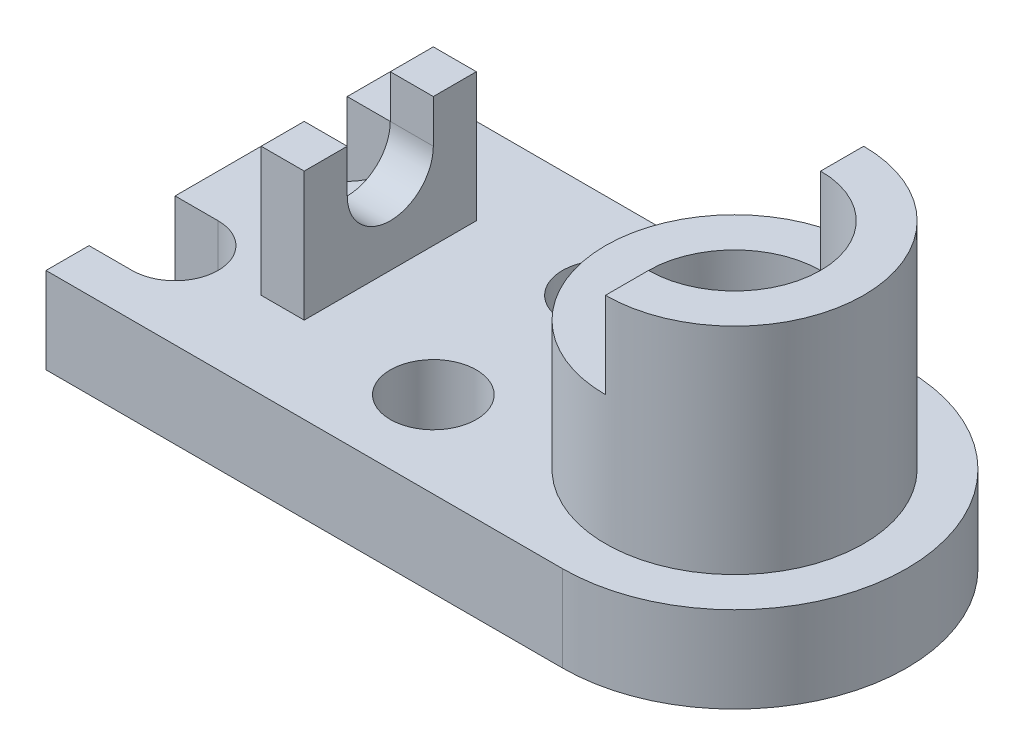
from build123d import *

# Parameters (mm, degrees)
BOSS_EXTRUDE1_DEPTH = 20
CUT_EXTRUDE1_DEPTH  = 20
SKETCH4_R           = 10
CUT_EXTRUDE2_DEPTH  = 20
SKETCH5_R           = 20
BOSS_EXTRUDE2_DEPTH = 20
SKETCH6_R           = 30
BOSS_EXTRUDE3_DEPTH = 30
SKETCH7_R           = 20
CUT_EXTRUDE3_DEPTH  = 10
SKETCH8_R           = 10
CUT_EXTRUDE4_DEPTH  = 72
BOSS_EXTRUDE4_DEPTH = 20
SKETCH10_W          = 10
SKETCH10_H          = 40
BOSS_EXTRUDE5_DEPTH = 30
CUT_EXTRUDE5_DEPTH  = 30


with BuildPart() as part:
    # Sketch2 → Boss-Extrude1 (new body)
    with BuildSketch(Plane(origin=(0, 0, 0), x_dir=(1, 0, 0), z_dir=(0, 1, 0))):
        with BuildLine():
            Line((0, 40), (0, -40))
            Line((0, -40), (120, -40))
            ThreePointArc((120, -40), (160, 0), (120, 40))
            Line((120, 40), (0, 40))
        make_face()
    extrude(amount=BOSS_EXTRUDE1_DEPTH)

    # Sketch3 → Cut-Extrude1 (cut)
    with BuildSketch(Plane(origin=(0, 20, 0), x_dir=(1, 0, 0), z_dir=(0, 1, 0))):
        with BuildLine():
            Line((0, 30), (10, 30))
            ThreePointArc((10, 30), (20, 20), (10, 10))
            Line((10, 10), (0, 10))
            Line((0, 10), (0, 30))
        make_face()
        with BuildLine():
            Line((0, -10), (10, -10))
            ThreePointArc((10, -10), (20, -20), (10, -30))
            Line((10, -30), (0, -30))
            Line((0, -30), (0, -10))
        make_face()
    extrude(amount=-CUT_EXTRUDE1_DEPTH, mode=Mode.SUBTRACT)

    # Sketch4 → Cut-Extrude2 (cut)
    with BuildSketch(Plane(origin=(0, 20, 0), x_dir=(1, 0, 0), z_dir=(0, 1, 0))):
        with Locations(Location((70, 20, 0), (0, 0, 270))):
            Circle(SKETCH4_R)
        with Locations(Location((70, -20, 0), (0, 0, 270))):
            Circle(SKETCH4_R)
    extrude(amount=-CUT_EXTRUDE2_DEPTH, mode=Mode.SUBTRACT)

    # Sketch5 → Boss-Extrude2 (add)
    with BuildSketch(Plane(origin=(0, 20, 0), x_dir=(1, 0, 0), z_dir=(0, 1, 0))):
        with Locations(Location((120, 0, 0), (0, 0, 90))):
            Circle(SKETCH5_R)
    extrude(amount=BOSS_EXTRUDE2_DEPTH)

    # Sketch6 → Boss-Extrude3 (add)
    with BuildSketch(Plane(origin=(0, 20, 0), x_dir=(1, 0, 0), z_dir=(0, 1, 0))):
        with Locations(Location((120, 0, 0), (0, 0, 90))):
            Circle(SKETCH6_R)
    extrude(amount=BOSS_EXTRUDE3_DEPTH)

    # Sketch7 → Cut-Extrude3 (cut)
    with BuildSketch(Plane(origin=(0, 50, 0), x_dir=(1, 0, 0), z_dir=(0, 1, 0))):
        with Locations(Location((120, 0, 0), (0, 0, 270))):
            Circle(SKETCH7_R)
    extrude(amount=-CUT_EXTRUDE3_DEPTH, mode=Mode.SUBTRACT)

    # Sketch8 → Cut-Extrude4 (cut)
    with BuildSketch(Plane(origin=(0, 40, 0), x_dir=(1, 0, 0), z_dir=(0, 1, 0))):
        with Locations(Location((120, 0, 0), (0, 0, 270))):
            Circle(SKETCH8_R)
    extrude(amount=-CUT_EXTRUDE4_DEPTH, mode=Mode.SUBTRACT)

    # Sketch9 → Boss-Extrude4 (add)
    with BuildSketch(Plane(origin=(0, 50, 0), x_dir=(1, 0, 0), z_dir=(0, 1, 0))):
        with BuildLine():
            Line((120, 20), (120, 30))
            ThreePointArc((120, 30), (150, 0), (120, -30))
            Line((120, -30), (120, -20))
            ThreePointArc((120, -20), (140, 0), (120, 20))
        make_face()
    extrude(amount=BOSS_EXTRUDE4_DEPTH)

    # Sketch10 → Boss-Extrude5 (add)
    with BuildSketch(Plane(origin=(0, 20, 0), x_dir=(1, 0, 0), z_dir=(0, 1, 0))):
        with Locations((35, 0)):
            Rectangle(SKETCH10_W, SKETCH10_H)
    extrude(amount=BOSS_EXTRUDE5_DEPTH)

    # Sketch11 → Cut-Extrude5 (cut)
    with BuildSketch(Plane.ZY.offset(-30)):
        with BuildLine():
            Line((-10, 50), (-10, 40))
            ThreePointArc((-10, 40), (0, 30), (10, 40))
            Line((10, 40), (10, 50))
            Line((10, 50), (-10, 50))
        make_face()
    extrude(amount=-CUT_EXTRUDE5_DEPTH, mode=Mode.SUBTRACT)


solid = part.part
